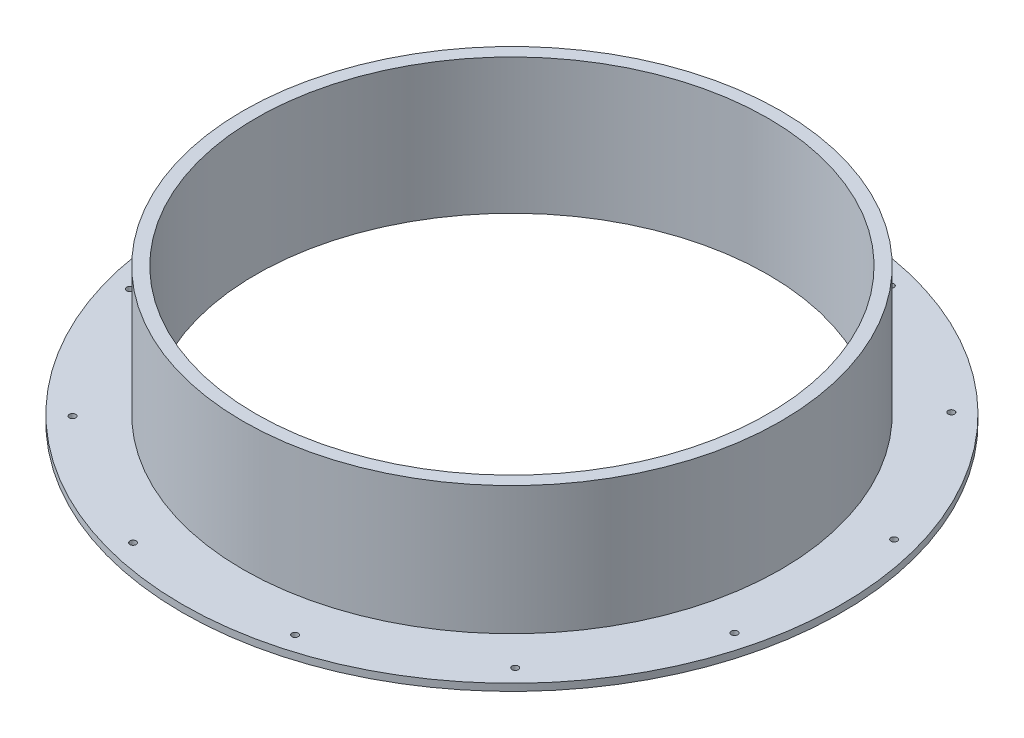
from build123d import *

# Parameters (mm, degrees)
SKETCH3_R                = 40.005
BOSS_EXTRUDE1_DEPTH      = 20.14
SKETCH4_R                = 38.1
CUT_EXTRUDE1_DEPTH       = 20.14
SKETCH2_R                = 49.03
BOSS_EXTRUDE2_DEPTH      = 1.05
SKETCH6_R                = 38.1
CUT_EXTRUDE2_DEPTH       = 1.05
M1_2X0_25_TAPPED_HOLE2_D = 0.95


with BuildPart() as part:
    # Sketch3 → Boss-Extrude1 (new body)
    with BuildSketch(Plane(origin=(0, 0, 0), x_dir=(1, 0, 0), z_dir=(0, 1, 0))):
        Circle(SKETCH3_R)
    extrude(amount=BOSS_EXTRUDE1_DEPTH)

    # Sketch4 → Cut-Extrude1 (cut)
    with BuildSketch(Plane(origin=(0, 20.14, 0), x_dir=(1, 0, 0), z_dir=(0, 1, 0))):
        Circle(SKETCH4_R)
    extrude(amount=-CUT_EXTRUDE1_DEPTH, mode=Mode.SUBTRACT)

    # Sketch2 → Boss-Extrude2 (add)
    with BuildSketch(Plane(origin=(0, 0, 0), x_dir=(1, 0, 0), z_dir=(0, 1, 0))):
        Circle(SKETCH2_R)
    extrude(amount=BOSS_EXTRUDE2_DEPTH)

    # Sketch6 → Cut-Extrude2 (cut)
    with BuildSketch(Plane(origin=(0, 1.05, 0), x_dir=(1, 0, 0), z_dir=(0, 1, 0))):
        Circle(SKETCH6_R)
    extrude(amount=-CUT_EXTRUDE2_DEPTH, mode=Mode.SUBTRACT)

    # M1.2x0.25 Tapped Hole2 (through all)
    with Locations(Plane(origin=(-12.298859085, 1.05, -44.559581921), x_dir=(0, 0, 1), z_dir=(0, 1, 0))):
        with Locations((0, 0), (-0.179575061, 23.927525232), (11.62866746, 44.739161663), (32.260724597, 56.858437128), (56.188247767, 57.038018412), (76.999884487, 45.229773054), (89.119161163, 24.597717695), (89.298738325, 0.670192913), (77.49049699, -20.141443547), (56.858440891, -32.260723471), (32.930915763, -32.440301841), (12.119282142, -20.63205416)):
            Hole(M1_2X0_25_TAPPED_HOLE2_D / 2)


solid = part.part
